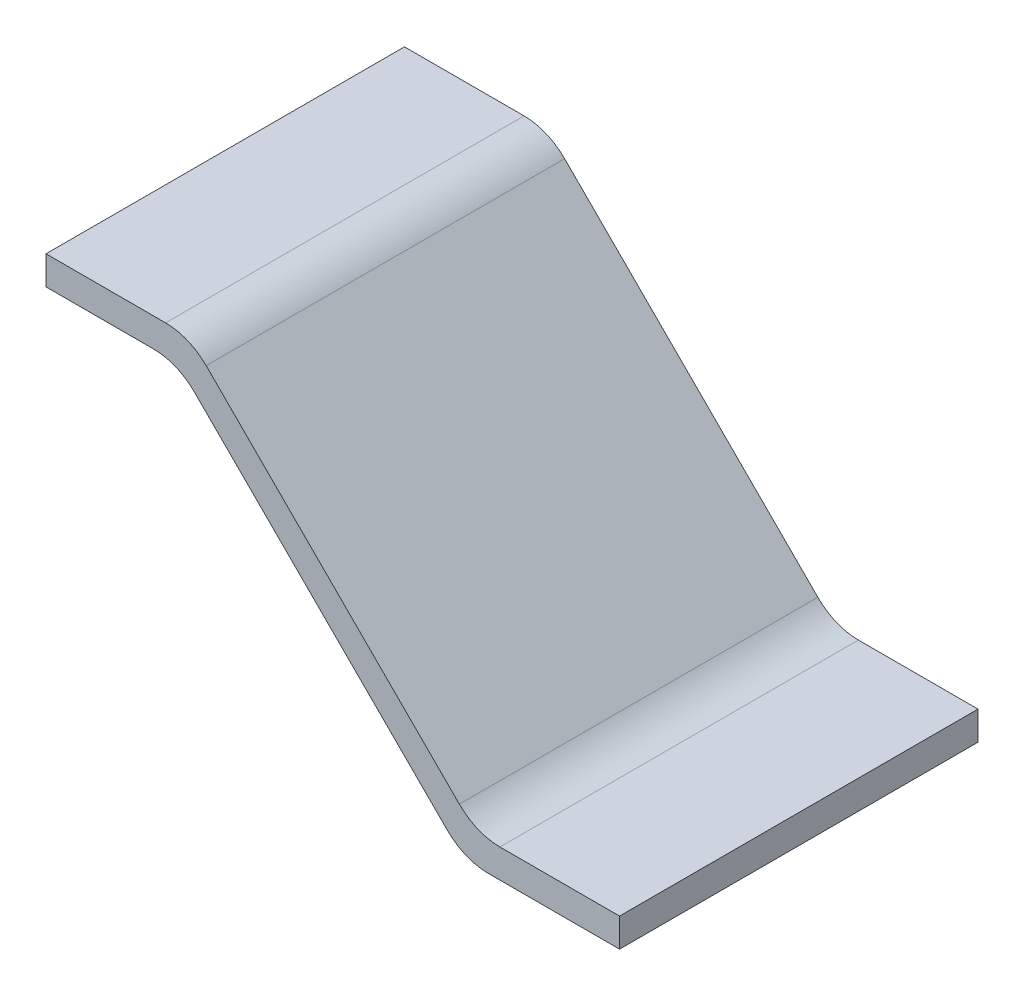
from build123d import *

# Parameters (mm, degrees)
BOSS_EXTRUDE1_DEPTH = 0.625
FILLET4_R           = 0.2


with BuildPart() as part:
    # Sketch4 → Boss-Extrude1 (new body, symmetric)
    with BuildSketch(Plane.XY):
        Polygon((0, 0), (0.5, 0), (1.5, -1), (2, -1), (2, -1.1), (1.458578644, -1.1), (0.458578644, -0.1), (0, -0.1), align=None)
    extrude(amount=BOSS_EXTRUDE1_DEPTH, both=True)

    # Fillet4
    fillet4_edges = [part.edges().sort_by_distance(p)[0] for p in [
        (0.5, 0, 0),
        (1.5, -1, 0),
        (1.458578644, -1.1, 0),
        (0.458578644, -0.1, 0),
    ]]
    fillet(fillet4_edges, radius=FILLET4_R)


solid = part.part
